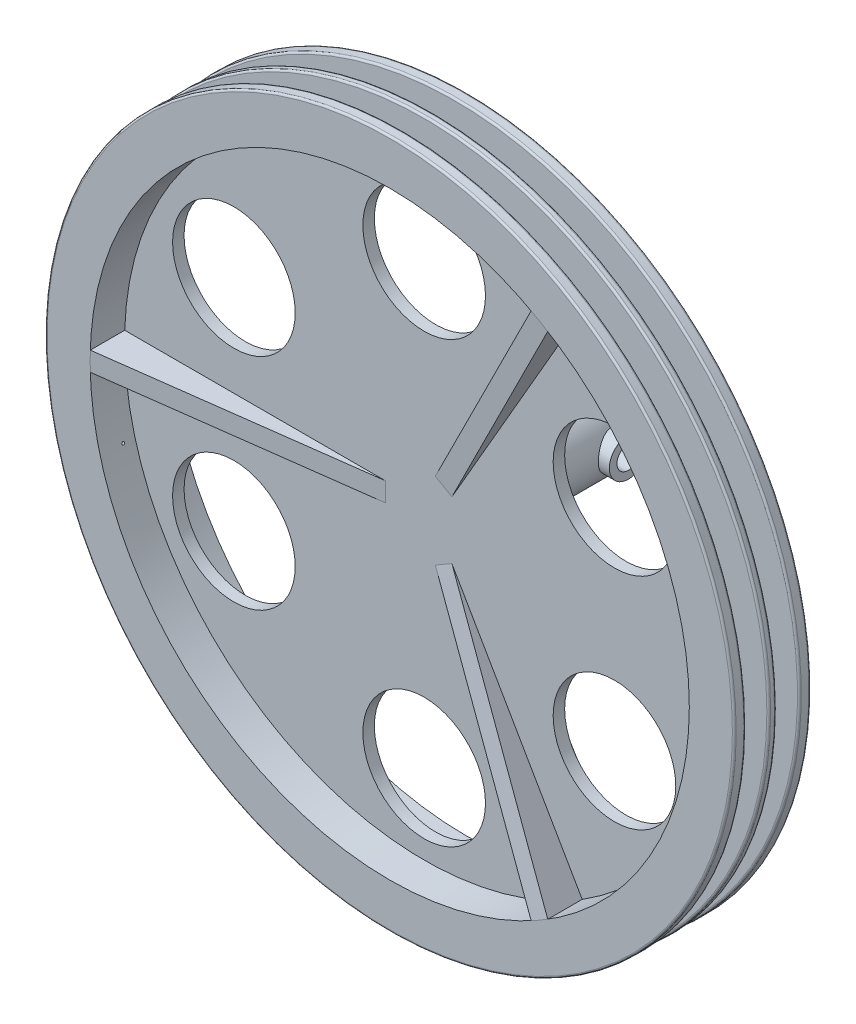
from build123d import *

# Parameters (mm, degrees)
SKETCH_2_R               = 10.9
SKETCH_2_R_2             = 9
EXTRUDE_1_DEPTH          = 42.2
SKETCH_14_R              = 80
EXTRUDE_4_DEPTH          = 3
EXTRUDE_START            = 5
SKETCH_15_R              = 80
SKETCH_15_R_2            = 78.25
EXTRUDE_5_DEPTH          = 5
SKETCH_16_R              = 80
SKETCH_16_R_2            = 78.25
EXTRUDE_6_DEPTH          = 6
EXTRUDE_START_2          = 3
SKETCH_17_R              = 90
SKETCH_17_R_2            = 78.25
EXTRUDE_7_DEPTH          = 3
SKETCH_19_R              = 16.01
CUT_EXTRUDE_3_DEPTH      = 135.092654534
SKETCH_23_R              = 90
SKETCH_23_R_2            = 78.25
EXTRUDE_9_DEPTH          = 3
SKETCH_28_W              = 5.5
SKETCH_28_H              = 1.341908432
EXTRUDE_10_DEPTH         = 6
RIB_38_REACH             = 140.339
SKETCH_35_WALL_W         = 346.038810282
SKETCH_35_WALL_H         = 5
PATTERN_CIRCULAR_4_COUNT = 3
RIB_43_REACH             = 140.339
SKETCH_36_WALL_W         = 347.364557306
SKETCH_36_WALL_H         = 5
PATTERN_CIRCULAR_5_COUNT = 3
FILLET_1_R               = 0.5
SKETCH_52_R              = 90
SKETCH_52_R_2            = 80
EXTRUDE_14_DEPTH         = 1
FILLET_3_R               = 0.5
CUT_EXTRUDE_7_DEPTH      = 15
CUT_EXTRUDE_7_DEPTH_BACK = 15
SKETCH_59_R              = 3
EXTRUDE_START_3          = 6.6
SKETCH_71_R              = 10.9
EXTRUDE_17_DEPTH         = 6.6
SKETCH_72_R              = 5
EXTRUDE_19_DEPTH         = 27.5
CUT_EXTRUDE_8_DEPTH      = 20
SKETCH_77_R              = 3
CUT_EXTRUDE_9_DEPTH      = 27.5
SKETCH_82_R              = 0.35
CUT_EXTRUDE_10_DEPTH     = 20
CUT_EXTRUDE_START        = 20
SKETCH_83_R              = 0.35
CUT_EXTRUDE_11_DEPTH     = 20


with BuildPart() as part:
    # 草图2 → 凸台-拉伸1 (new body)
    with BuildSketch(Plane.XY):
        Circle(SKETCH_2_R)
        Circle(SKETCH_2_R_2, mode=Mode.SUBTRACT)
    extrude(amount=EXTRUDE_1_DEPTH)

    # 草图14 → 凸台-拉伸4 (add)
    with BuildSketch(Plane.XY.offset(42.2)):
        Circle(SKETCH_14_R)
    extrude(amount=EXTRUDE_4_DEPTH)

    # 草图15 → 凸台-拉伸5 (add)
    with BuildSketch(Plane(origin=(0, 0, 42.2), x_dir=(-1, 0, 0), z_dir=(0, 0, -1)).offset(EXTRUDE_START)):
        Circle(SKETCH_15_R)
        Circle(SKETCH_15_R_2, mode=Mode.SUBTRACT)
    extrude(amount=-EXTRUDE_5_DEPTH)

    # 草图16 → 凸台-拉伸6 (add)
    with BuildSketch(Plane.XY.offset(45.2)):
        Circle(SKETCH_16_R)
        Circle(SKETCH_16_R_2, mode=Mode.SUBTRACT)
    extrude(amount=EXTRUDE_6_DEPTH)

    # 草图17 → 凸台-拉伸7 (add)
    with BuildSketch(Plane(origin=(0, 0, 37.2), x_dir=(-1, 0, 0), z_dir=(0, 0, -1)).offset(EXTRUDE_START_2)):
        Circle(SKETCH_17_R)
        Circle(SKETCH_17_R_2, mode=Mode.SUBTRACT)
    extrude(amount=-EXTRUDE_7_DEPTH)

    # 草图19 → 切除-拉伸3 (cut, through all)
    with BuildSketch(Plane(origin=(0, 0, 42.2), x_dir=(-1, 0, 0), z_dir=(0, 0, -1))):
        with Locations((0, 57.386198437)):
            Circle(SKETCH_19_R)
        with Locations((49.697905673, 28.693099218)):
            Circle(SKETCH_19_R)
        with Locations((49.697905673, -28.693099218)):
            Circle(SKETCH_19_R)
        with Locations((0, -57.386198437)):
            Circle(SKETCH_19_R)
        with Locations((-49.697905673, -28.693099218)):
            Circle(SKETCH_19_R)
        with Locations((-49.697905673, 28.693099218)):
            Circle(SKETCH_19_R)
    extrude(amount=-CUT_EXTRUDE_3_DEPTH, mode=Mode.SUBTRACT)

    # 草图23 → 凸台-拉伸9 (add)
    with BuildSketch(Plane.XY.offset(51.2)):
        Circle(SKETCH_23_R)
        Circle(SKETCH_23_R_2, mode=Mode.SUBTRACT)
    extrude(amount=EXTRUDE_9_DEPTH)

    # 草图28 → 凸台-拉伸10 (add)
    with BuildSketch(Plane(origin=(0, 0, 0), x_dir=(-1, 0, 0), z_dir=(0, 0, -1))):
        with Locations((0, 8.470954216)):
            Rectangle(SKETCH_28_W, SKETCH_28_H)
    extrude(amount=-EXTRUDE_10_DEPTH)

    # 草图35 wall → 筋38 (add, up to next)
    with BuildSketch(Plane(origin=(22.2875, -38.603082374, 34.811180252), x_dir=(-0.499917670372, 0.865882804687, 0.018146387974), z_dir=(-0.009073193987, 0.015715232972, -0.999835340745)), mode=Mode.PRIVATE) as rib_38_sk1:
        Rectangle(SKETCH_35_WALL_W, SKETCH_35_WALL_H)
    rib_38_tool1 = extrude(rib_38_sk1.sketch, amount=-RIB_38_REACH, mode=Mode.PRIVATE) - part.part
    rib_38 = rib_38_tool1.solids().sort_by_distance((22.2875, -38.603082374, 34.811180252))[0]
    add(rib_38)

    # 阵列(圆周)4: 筋38 ×3 about axis
    pattern_circular_4_axis = Axis((0, 0, 34.2), (0, 0, -1))
    for i in range(1, PATTERN_CIRCULAR_4_COUNT):
        add(rib_38.rotate(pattern_circular_4_axis, i * 360 / PATTERN_CIRCULAR_4_COUNT))

    # 草图36 wall → 筋43 (add, up to next)
    with BuildSketch(Plane(origin=(22.101336683, -38.28063805, 49.7), x_dir=(-0.49568923688, 0.858558943042, -0.131029469065), z_dir=(0.065514734532, -0.113474848854, -0.991378473761)), mode=Mode.PRIVATE) as rib_43_sk1:
        Rectangle(SKETCH_36_WALL_W, SKETCH_36_WALL_H)
    rib_43_tool1 = extrude(rib_43_sk1.sketch, amount=RIB_43_REACH, mode=Mode.PRIVATE) - part.part
    rib_43 = rib_43_tool1.solids().sort_by_distance((22.101336683, -38.28063805, 49.7))[0]
    add(rib_43)

    # 阵列(圆周)5: 筋43 ×3 about axis
    pattern_circular_5_axis = Axis((0, 0, 54.2), (0, 0, 1))
    for i in range(1, PATTERN_CIRCULAR_5_COUNT):
        add(rib_43.rotate(pattern_circular_5_axis, i * 360 / PATTERN_CIRCULAR_5_COUNT))

    # 圆角1
    fillet_1_edges = [part.edges().sort_by_distance(p)[0] for p in [
        (90, 0, 37.2),
        (90, 0, 34.2),
        (-90, 0, 54.2),
        (-90, 0, 51.2),
    ]]
    fillet(fillet_1_edges, radius=FILLET_1_R)

    # 草图52 → 凸台-拉伸14 (add, symmetric)
    with BuildSketch(Plane.XY.offset(44.2)):
        Circle(SKETCH_52_R)
        Circle(SKETCH_52_R_2, mode=Mode.SUBTRACT)
    extrude(amount=EXTRUDE_14_DEPTH, both=True)

    # 圆角3
    fillet_3_edges = [part.edges().sort_by_distance(p)[0] for p in [
        (-90, 0, 45.2),
        (-90, 0, 43.2),
    ]]
    fillet(fillet_3_edges, radius=FILLET_3_R)

    # 草图59 → 切除-拉伸7 (cut, two sides: drawn at the far end of the back side and taken through both)
    with BuildSketch(Plane(origin=(0, 0, 0), x_dir=(0, 0, -1), z_dir=(1, 0, 0)).offset(-CUT_EXTRUDE_7_DEPTH_BACK)):
        with Locations((-5.6, 0)):
            Circle(SKETCH_59_R)
    extrude(amount=CUT_EXTRUDE_7_DEPTH + CUT_EXTRUDE_7_DEPTH_BACK, mode=Mode.SUBTRACT)

    # 草图71 → 凸台-拉伸17 (add)
    with BuildSketch(Plane(origin=(0, 0, 0), x_dir=(-1, 0, 0), z_dir=(0, 0, -1)).offset(EXTRUDE_START_3)):
        Circle(SKETCH_71_R)
        with BuildLine():
            Line((-2.75, 8.569568251), (-2.75, 7.8))
            Line((-2.75, 7.8), (2.75, 7.8))
            Line((2.75, 7.8), (2.75, 8.569568251))
            ThreePointArc((2.75, 8.569568251), (0, -9), (-2.75, 8.569568251))
        make_face(mode=Mode.SUBTRACT)
    extrude(amount=-EXTRUDE_17_DEPTH)

    # 草图72 → 凸台-拉伸19 (add)
    with BuildSketch(Plane.ZY.offset(13.75)):
        with Locations((5.6, 0)):
            Circle(SKETCH_72_R)
    extrude(amount=-EXTRUDE_19_DEPTH)

    # 草图76 → 切除-拉伸8 (cut)
    with BuildSketch(Plane(origin=(0, 0, -6.6), x_dir=(-1, 0, 0), z_dir=(0, 0, -1))):
        with BuildLine():
            Line((-2.75, 8.569568251), (-2.75, 7.8))
            Line((-2.75, 7.8), (2.75, 7.8))
            Line((2.75, 7.8), (2.75, 8.569568251))
            ThreePointArc((2.75, 8.569568251), (0, -9), (-2.75, 8.569568251))
        make_face()
    extrude(amount=-CUT_EXTRUDE_8_DEPTH, mode=Mode.SUBTRACT)

    # 草图77 → 切除-拉伸9 (cut)
    with BuildSketch(Plane.ZY.offset(13.75)):
        with Locations((5.6, 0)):
            Circle(SKETCH_77_R)
    extrude(amount=-CUT_EXTRUDE_9_DEPTH, mode=Mode.SUBTRACT)

    # 草图82 → 切除-拉伸10 (cut)
    with BuildSketch(Plane(origin=(-86.933324366, -23.293714059, 0), x_dir=(0, 0, 1), z_dir=(-0.9659258262890794, -0.258819045102479, 0))):
        with Locations((40.2, 0)):
            Circle(SKETCH_82_R)
        with Locations((48.2, 0)):
            Circle(SKETCH_82_R)
    extrude(amount=-CUT_EXTRUDE_10_DEPTH, mode=Mode.SUBTRACT)

    # 草图83 → 切除-拉伸11 (cut)
    with BuildSketch(Plane(origin=(86.933324366, 23.293714059, 0), x_dir=(0, 0, 1), z_dir=(-0.9659258262890794, -0.258819045102479, 0)).offset(CUT_EXTRUDE_START)):
        with Locations((40.2, 0)):
            Circle(SKETCH_83_R)
        with Locations((48.2, 0)):
            Circle(SKETCH_83_R)
    extrude(amount=-CUT_EXTRUDE_11_DEPTH, mode=Mode.SUBTRACT)


solid = part.part
